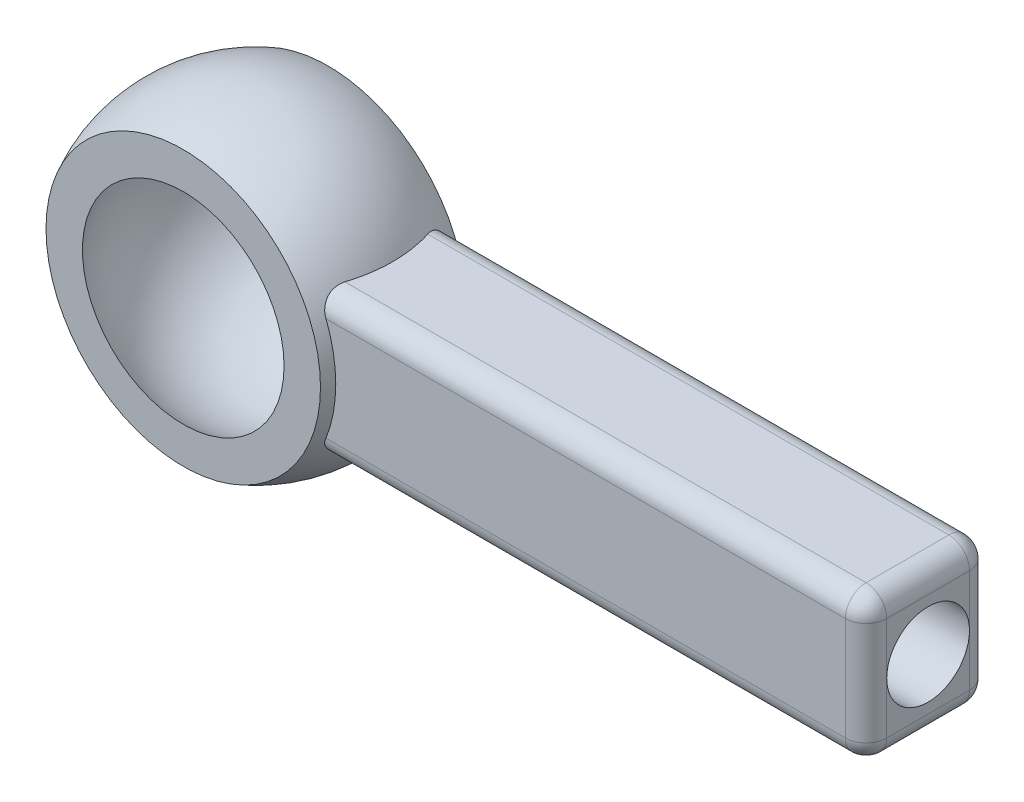
from build123d import *

# Parameters (mm, degrees)
EXTRUDE_1_DEPTH     = 1.5
FILLET_1_R          = 0.5
SKETCH_3_R          = 1
CUT_EXTRUDE_1_DEPTH = 5


with BuildPart() as part:
    # 草图1 → 旋转1 (revolve)
    with BuildSketch(Plane(origin=(0, 0, 0), x_dir=(1, 0, 0), z_dir=(0, 1, 0))):
        with BuildLine():
            Line((-2.436698586, 1.75), (-3.31662479, 1.75))
            ThreePointArc((-3.31662479, 1.75), (-3.75, 0), (-3.31662479, -1.75))
            Line((-3.31662479, -1.75), (-2.436698586, -1.75))
            ThreePointArc((-2.436698586, -1.75), (-3, 0), (-2.436698586, 1.75))
        make_face()
    revolve(axis=Axis((0, 0, 116.11690901), (0, 0, -1)))


with BuildPart() as body_2:
    # 草图2 → 凸台-拉伸1 (new body, symmetric)
    with BuildSketch(Plane.XY):
        with BuildLine():
            Line((3.31662479, -1.75), (16.25, -1.75))
            Line((16.25, -1.75), (16.25, 1.75))
            Line((16.25, 1.75), (3.31662479, 1.75))
            Line((3.31662479, 1.75), (2.817356917, 1.75))
            ThreePointArc((2.817356917, 1.75), (3.189366379, 0.909913239), (3.31662479, 0))
            ThreePointArc((3.31662479, 0), (3.189366379, -0.909913239), (2.817356917, -1.75))
            Line((2.817356917, -1.75), (3.31662479, -1.75))
        make_face()
    extrude(amount=EXTRUDE_1_DEPTH, both=True)

    # 圆角1
    fillet_1_edges = [body_2.edges().sort_by_distance(p)[0] for p in [
        (9.533678459, -1.75, 1.5),
        (16.25, 0, 1.5),
        (9.533678459, 1.75, 1.5),
        (9.533678459, 1.75, -1.5),
        (16.25, 0, -1.5),
        (9.533678459, -1.75, -1.5),
        (16.25, 1.75, 0),
        (16.25, -1.75, 0),
    ]]
    fillet(fillet_1_edges, radius=FILLET_1_R)

    # 草图3 → 切除-拉伸1 (cut)
    with BuildSketch(Plane(origin=(16.25, 0, 0), x_dir=(0, 0, -1), z_dir=(1, 0, 0))):
        Circle(SKETCH_3_R)
    extrude(amount=-CUT_EXTRUDE_1_DEPTH, mode=Mode.SUBTRACT)


solid = Compound([part.part, body_2.part])
